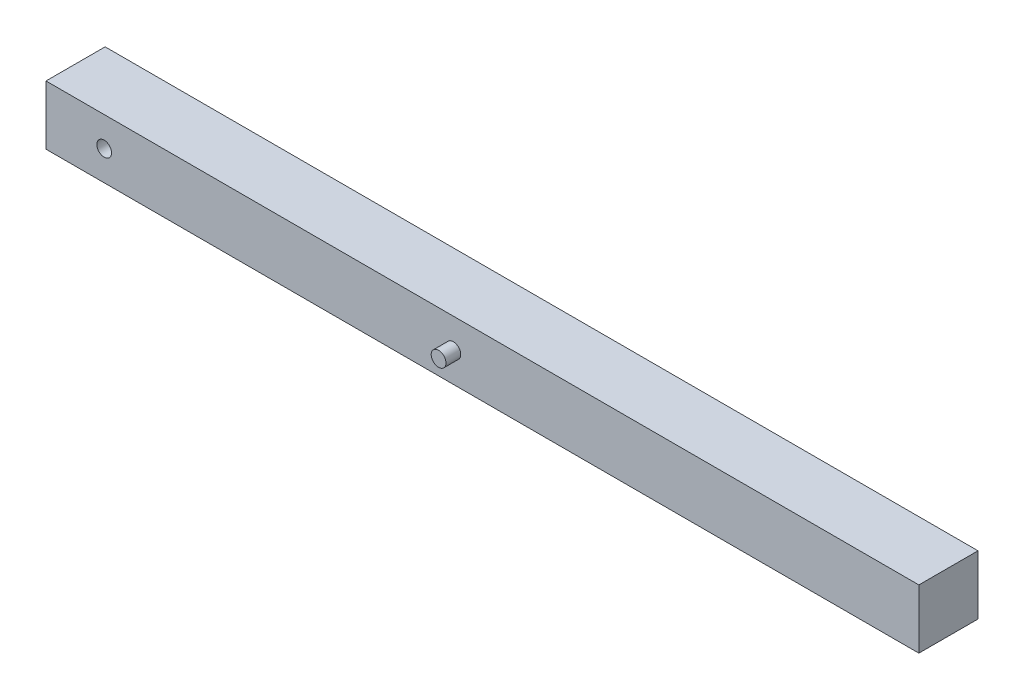
from build123d import *

# Parameters (mm, degrees)
SKETCH1_W           = 750
SKETCH1_H           = 50.8
SKETCH1_R           = 6.35
BOSS_EXTRUDE1_DEPTH = 50.8
SKETCH2_R           = 6.35
BOSS_EXTRUDE2_DEPTH = 12.7


with BuildPart() as part:
    # Sketch1 → Boss-Extrude1 (new body)
    with BuildSketch(Plane.XY):
        with Locations((335.619050288, -16.370527994)):
            Rectangle(SKETCH1_W, SKETCH1_H)
        with Locations((10.619050288, -16.370527994)):
            Circle(SKETCH1_R, mode=Mode.SUBTRACT)
    extrude(amount=BOSS_EXTRUDE1_DEPTH)

    # Sketch2 → Boss-Extrude2 (add)
    with BuildSketch(Plane.XY.offset(50.8)):
        with Locations((310.619050288, -16.370527994)):
            Circle(SKETCH2_R)
    extrude(amount=BOSS_EXTRUDE2_DEPTH)


solid = part.part
